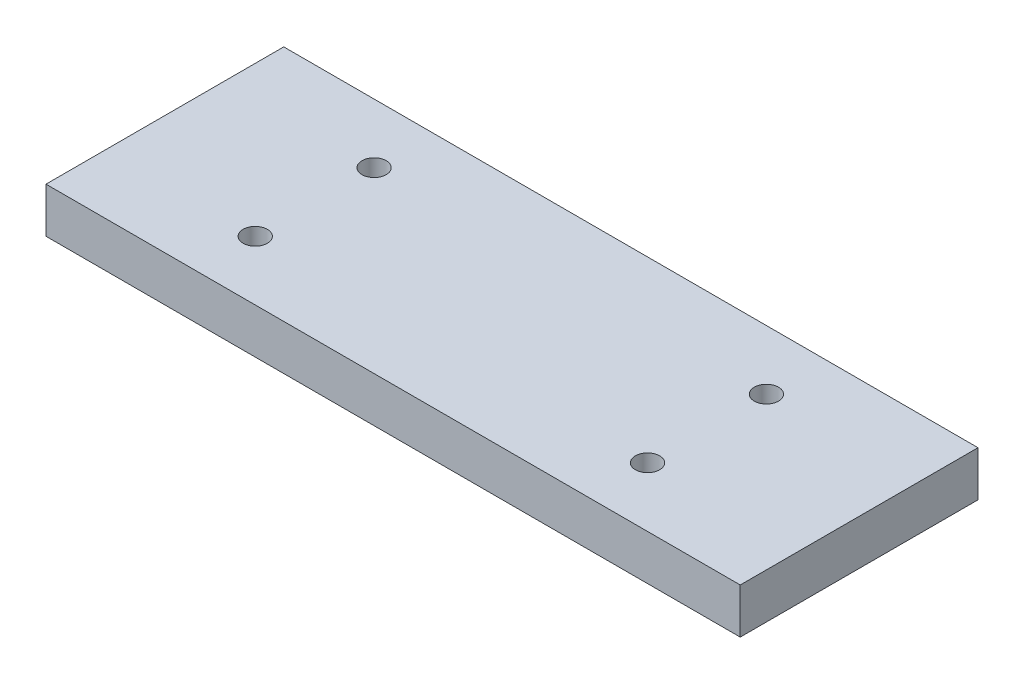
from build123d import *

# Parameters (mm, degrees)
SCHIZZO1_W                   = 292
SCHIZZO1_H                   = 100
ESTRUSIONE_ESTRUSIONE1_DEPTH = 19
FORO_FILETTATO_M12_1_D       = 10.2


with BuildPart() as part:
    # Schizzo1 → Estrusione-Estrusione1 (new body)
    with BuildSketch(Plane(origin=(0, 0, 0), x_dir=(1, 0, 0), z_dir=(0, 1, 0))):
        Rectangle(SCHIZZO1_W, SCHIZZO1_H)
    extrude(amount=ESTRUSIONE_ESTRUSIONE1_DEPTH)

    # Foro filettato M12-1 (through all)
    with Locations(Plane(origin=(-83, 19, -25), x_dir=(0, 0, 1), z_dir=(0, 1, 0))):
        with Locations((0, 0), (0, 165), (50, 165), (50, 0)):
            Hole(FORO_FILETTATO_M12_1_D / 2)


solid = part.part
